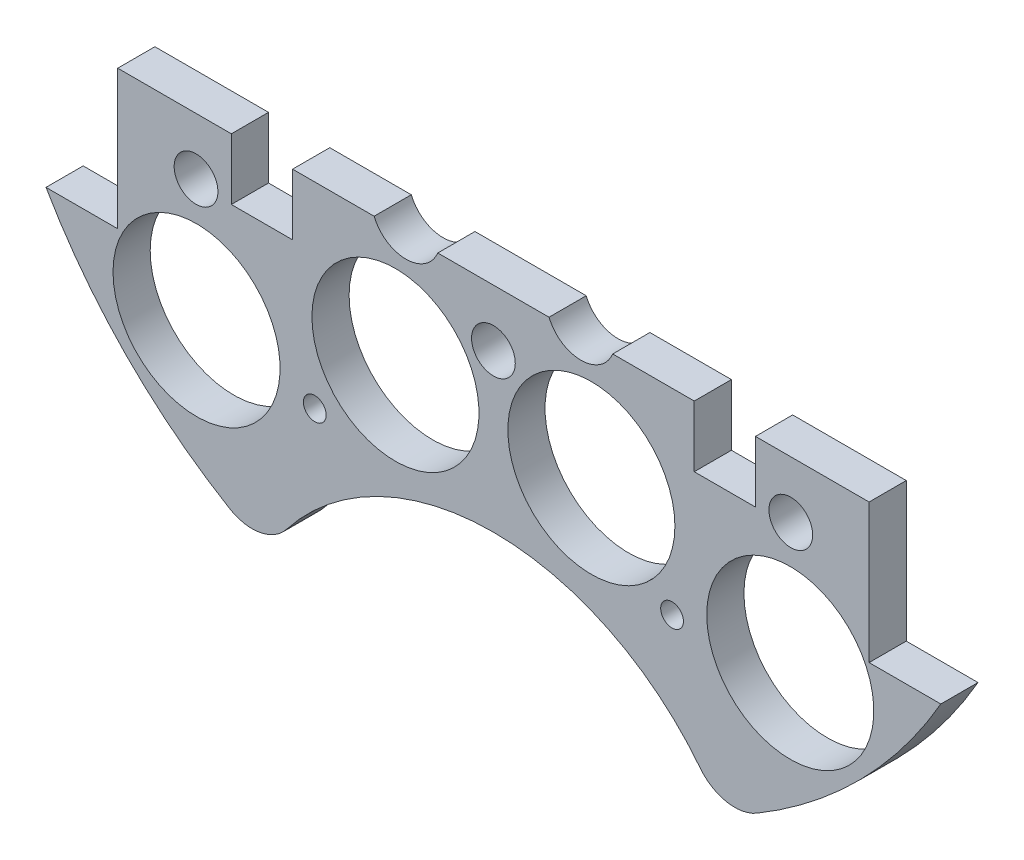
from build123d import *

# Parameters (mm, degrees)
SKETCH1_R                 = 1.651
BOSS_EXTRUDE2_DEPTH       = 5.3975
SKETCH2_R                 = 1.143
CUT_EXTRUDE1_DEPTH        = 6.3975
SKETCH3_R                 = 12.1285
CUT_EXTRUDE2_DEPTH        = 6.3975
SKETCH4_W                 = 28.562713242
SKETCH4_H                 = 11.677503754
BOSS_EXTRUDE3_DEPTH       = 5.3975
SKETCH5_W                 = 216.7214489
SKETCH5_H                 = 130.569220634
CUT_EXTRUDE4_DEPTH        = 6.3975
SKETCH6_R                 = 38.1
CUT_EXTRUDE5_DEPTH        = 60.96
FILLET1_R                 = 6.35
FILLET2_R                 = 6.35
SKETCH102_W               = 8.89
SKETCH102_H               = 8.89
CUT_EXTRUDE101_DEPTH      = 6.3975001
SKETCH105_R               = 5
CUT_EXTRUDE104_DEPTH      = 10
SKETCH106_R               = 3.175
CUT_EXTRUDE105_DEPTH      = 103.378
CUT_EXTRUDE105_DEPTH_BACK = 1
SKETCH158_R               = 1.651
CUT_EXTRUDE157_DEPTH      = 97.79


with BuildPart() as part:
    # Sketch1 → Boss-Extrude2 (new body)
    with BuildSketch(Plane.XY):
        with BuildLine():
            Line((-64.964441474, 37.338), (-54.550441474, 37.338))
            Line((-54.550441474, 37.338), (-54.550441474, -37.338))
            Line((-54.550441474, -37.338), (-64.964441474, -37.338))
            ThreePointArc((-64.964441474, -37.338), (0, -74.93), (64.964441474, -37.338))
            Line((64.964441474, -37.338), (54.550441474, -37.338))
            Line((54.550441474, -37.338), (54.550441474, 37.338))
            Line((54.550441474, 37.338), (64.964441474, 37.338))
            ThreePointArc((64.964441474, 37.338), (0, 74.93), (-64.964441474, 37.338))
        make_face()
        with Locations((-46.482, 11.049)):
            Circle(SKETCH1_R, mode=Mode.SUBTRACT)
        with Locations((-21.083270032, 10.795)):
            Circle(SKETCH1_R, mode=Mode.SUBTRACT)
        with Locations((-21.083270032, -10.795)):
            Circle(SKETCH1_R, mode=Mode.SUBTRACT)
        with Locations((-46.482, -11.049)):
            Circle(SKETCH1_R, mode=Mode.SUBTRACT)
        with Locations((46.482, -11.049)):
            Circle(SKETCH1_R, mode=Mode.SUBTRACT)
        with Locations((21.083270032, -10.795)):
            Circle(SKETCH1_R, mode=Mode.SUBTRACT)
        with Locations((21.083270032, 10.795)):
            Circle(SKETCH1_R, mode=Mode.SUBTRACT)
        with Locations((46.482, 11.049)):
            Circle(SKETCH1_R, mode=Mode.SUBTRACT)
    extrude(amount=BOSS_EXTRUDE2_DEPTH)

    # Sketch2 → Cut-Extrude1 (cut, through all)
    with BuildSketch(Plane.XY.offset(5.3975)):
        with Locations((-6.731, 62.23)):
            Circle(SKETCH2_R)
        with Locations((6.731, 62.23)):
            Circle(SKETCH2_R)
    extrude(amount=-CUT_EXTRUDE1_DEPTH, mode=Mode.SUBTRACT)

    # Sketch3 → Cut-Extrude2 (cut, through all)
    with BuildSketch(Plane(origin=(0, 0, 0), x_dir=(-1, 0, 0), z_dir=(0, 0, -1))):
        with Locations((-43.105229381, -43.105229381)):
            Circle(SKETCH3_R)
        with Locations((14.224, -34.29)):
            Circle(SKETCH3_R)
        with Locations((14.224, 34.29)):
            Circle(SKETCH3_R)
        with Locations((-43.105229381, 43.105229381)):
            Circle(SKETCH3_R)
        with Locations((43.105229381, 43.105229381)):
            Circle(SKETCH3_R)
        with Locations((-14.224, 34.29)):
            Circle(SKETCH3_R)
        with Locations((-14.224, -34.29)):
            Circle(SKETCH3_R)
        with Locations((43.105229381, -43.105229381)):
            Circle(SKETCH3_R)
    extrude(amount=-CUT_EXTRUDE2_DEPTH, mode=Mode.SUBTRACT)

    # Sketch4 → Boss-Extrude3 (add)
    with BuildSketch(Plane(origin=(0, 0, 0), x_dir=(-1, 0, 0), z_dir=(0, 0, -1))):
        with Locations((-1.488809975, 62.152540216)):
            Rectangle(SKETCH4_W, SKETCH4_H)
    extrude(amount=-BOSS_EXTRUDE3_DEPTH)

    # Sketch5 → Cut-Extrude4 (cut, through all)
    with BuildSketch(Plane(origin=(0, 0, 0), x_dir=(-1, 0, 0), z_dir=(0, 0, -1))):
        with Locations((23.316688373, 48.139610317)):
            Rectangle(SKETCH5_W, SKETCH5_H)
    extrude(amount=-CUT_EXTRUDE4_DEPTH, mode=Mode.SUBTRACT)

    # Sketch6 → Cut-Extrude5 (cut)
    with BuildSketch(Plane(origin=(0, 0, 0), x_dir=(-1, 0, 0), z_dir=(0, 0, -1))):
        with Locations((0, -86.312058398)):
            Circle(SKETCH6_R)
    extrude(amount=-CUT_EXTRUDE5_DEPTH, mode=Mode.SUBTRACT)

    # Fillet1
    fillet1_edges = [part.edges().sort_by_distance(p)[0] for p in [
        (-33.000960548, -67.271401821, 2.69875),
    ]]
    fillet(fillet1_edges, radius=FILLET1_R)

    # Fillet2
    fillet2_edges = [part.edges().sort_by_distance(p)[0] for p in [
        (33.000960548, -67.271401821, 2.69875),
    ]]
    fillet(fillet2_edges, radius=FILLET2_R)

    # Sketch102 → Cut-Extrude101 (cut, through all)
    with BuildSketch(Plane(origin=(0, 0, 0), x_dir=(-1, 0, 0), z_dir=(0, 0, -1))):
        with Locations((-33.605441474, -21.59)):
            Rectangle(SKETCH102_W, SKETCH102_H)
        with Locations((33.605441474, -21.59)):
            Rectangle(SKETCH102_W, SKETCH102_H)
    extrude(amount=-CUT_EXTRUDE101_DEPTH, mode=Mode.SUBTRACT)

    # Sketch105 → Cut-Extrude104 (cut)
    with BuildSketch(Plane(origin=(0, 0, 0), x_dir=(-1, 0, 0), z_dir=(0, 0, -1))):
        with Locations((-12.7, -15.24)):
            Circle(SKETCH105_R)
        with Locations((12.7, -15.24)):
            Circle(SKETCH105_R)
    extrude(amount=-CUT_EXTRUDE104_DEPTH, mode=Mode.SUBTRACT)

    # Sketch106 → Cut-Extrude105 (cut, two sides)
    with BuildSketch(Plane(origin=(30.092005081, 4.08352975, 22.2885), x_dir=(-1, 0, 0), z_dir=(0, 0, -1))) as cut_extrude105_sk:
        with Locations((73.272005081, -29.48352975)):
            Circle(SKETCH106_R)
        with Locations((30.092005081, -29.48352975)):
            Circle(SKETCH106_R)
        with Locations((-13.087994919, -29.48352975)):
            Circle(SKETCH106_R)
    extrude(amount=CUT_EXTRUDE105_DEPTH, mode=Mode.SUBTRACT)
    extrude(cut_extrude105_sk.sketch, amount=-CUT_EXTRUDE105_DEPTH_BACK, mode=Mode.SUBTRACT)

    # Sketch158 → Cut-Extrude157 (cut)
    with BuildSketch(Plane(origin=(30.092005081, 4.08352975, -24.638), x_dir=(-1, 0, 0), z_dir=(0, 0, -1))):
        with Locations((4.154396091, -49.728759131)):
            Circle(SKETCH158_R)
        with Locations((56.02961407, -49.728759131)):
            Circle(SKETCH158_R)
    extrude(amount=-CUT_EXTRUDE157_DEPTH, mode=Mode.SUBTRACT)


solid = part.part
